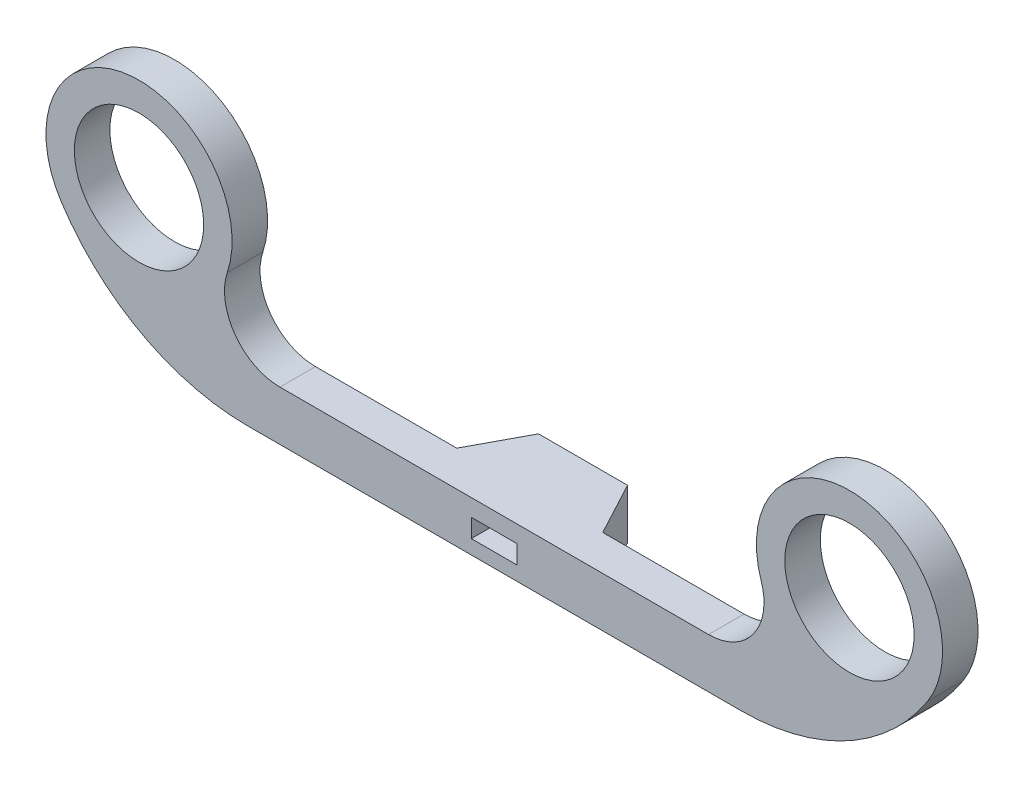
from build123d import *

# Parameters (mm, degrees)
SKETCH1_R                      = 5.7785
SKETCH1_W                      = 4.1
SKETCH1_H                      = 1.651
BOSS_EXTRUDE1_DEPTH            = 12.7
CUT_EXTRUDE1_REACH             = 6.445
CUT_EXTRUDE1_DIRECTION_2_DEPTH = 18.4625


with BuildPart() as part:
    # Sketch1 → Boss-Extrude1 (new body)
    with BuildSketch(Plane.XY):
        with BuildLine():
            Line((-22.056518803, 18.161), (22.056518803, 18.161))
            ThreePointArc((22.056518803, 18.161), (31.546886224, 20.574211288), (38.731794688, 27.227612888))
            ThreePointArc((38.731794688, 27.227612888), (32.803412582, 40.00153102), (23.855967837, 29.126700844))
            ThreePointArc((23.855967837, 29.126700844), (23.171856155, 24.662896524), (19.151565806, 22.606))
            Line((19.151565806, 22.606), (-19.151565806, 22.606))
            ThreePointArc((-19.151565806, 22.606), (-23.171856155, 24.662896524), (-23.855967837, 29.126700844))
            ThreePointArc((-23.855967837, 29.126700844), (-32.803412582, 40.00153102), (-38.731794688, 27.227612888))
            ThreePointArc((-38.731794688, 27.227612888), (-31.546886224, 20.574211288), (-22.056518803, 18.161))
        make_face()
        with Locations((-31.75, 31.75)):
            Circle(SKETCH1_R, mode=Mode.SUBTRACT)
        with Locations((31.75, 31.75)):
            Circle(SKETCH1_R, mode=Mode.SUBTRACT)
        with Locations((0, 20.2565)):
            Rectangle(SKETCH1_W, SKETCH1_H, mode=Mode.SUBTRACT)
    extrude(amount=BOSS_EXTRUDE1_DEPTH)

    # Sketch2 → Cut-Extrude1 (cut, up to next)
    with BuildSketch(Plane(origin=(0, 22.606, 0), x_dir=(1, 0, 0), z_dir=(0, 1, 0)), mode=Mode.PRIVATE) as cut_extrude1_sk1:
        Polygon((-46.157400287, -9.525), (-6.524655543, -9.525), (-3.978583924, -4.7625), (3.978583924, -4.7625), (6.524655543, -9.525), (46.157400287, -9.525), (46.157400287, 7.651360298), (-46.157400287, 7.651360298), align=None)
    cut_extrude1_tool1 = extrude(cut_extrude1_sk1.sketch, amount=-CUT_EXTRUDE1_REACH, mode=Mode.PRIVATE) & part.part
    add(cut_extrude1_tool1.solids().sort_by_distance((0, 22.606, 0.728365))[0], mode=Mode.SUBTRACT)

    # Sketch2 → Cut-Extrude1 direction 2 (cut)
    with BuildSketch(Plane(origin=(0, 22.606, 0), x_dir=(1, 0, 0), z_dir=(0, 1, 0))):
        Polygon((-46.157400287, -9.525), (-6.524655543, -9.525), (-3.978583924, -4.7625), (3.978583924, -4.7625), (6.524655543, -9.525), (46.157400287, -9.525), (46.157400287, 7.651360298), (-46.157400287, 7.651360298), align=None)
    extrude(amount=CUT_EXTRUDE1_DIRECTION_2_DEPTH, mode=Mode.SUBTRACT)


solid = part.part
